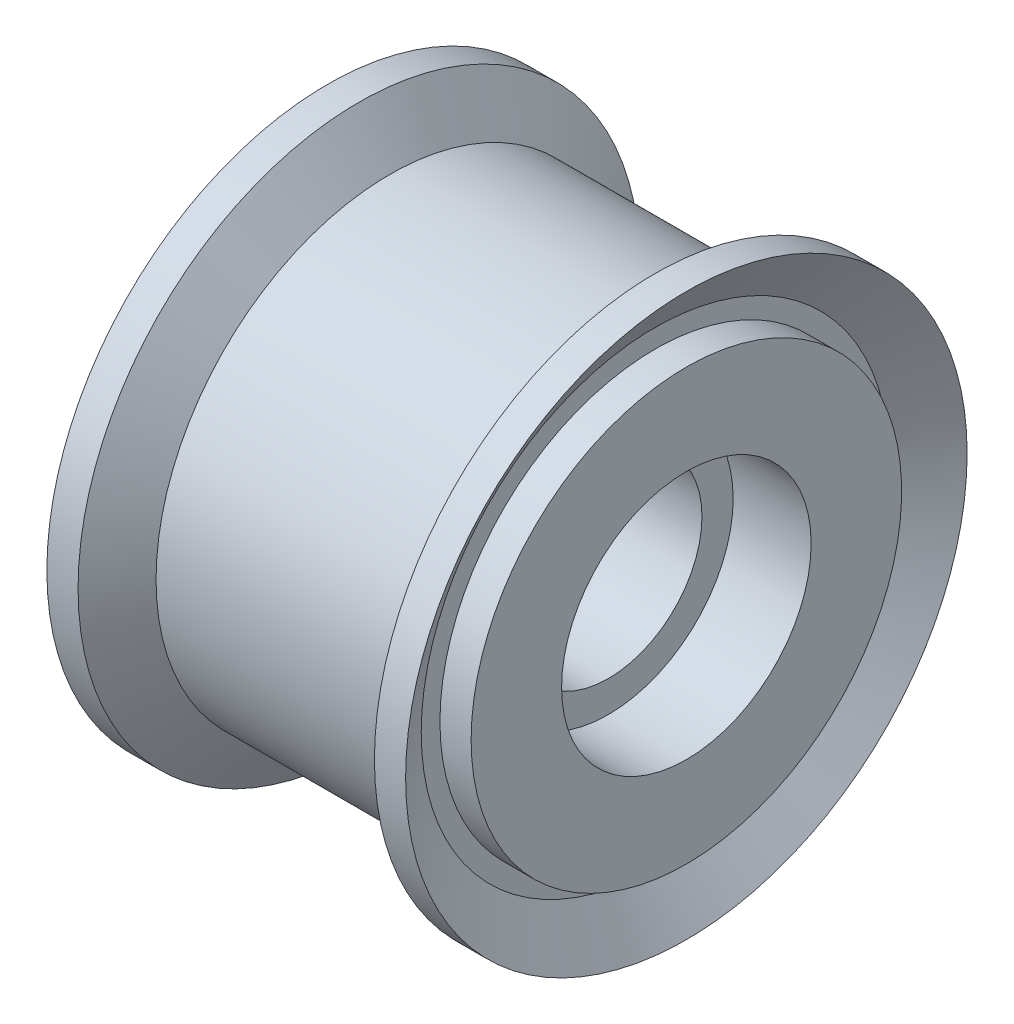
from build123d import *


with BuildPart() as part:
    # Sketch1 → Revolve1 (revolve)
    with BuildSketch(Plane.XY):
        Polygon((-5.75, 9), (-4.75, 7.5), (-4.75, 6.9), (-5.75, 6.9), (-5.75, 4), (-3.25, 4), (-3.25, 3), (3.25, 3), (3.25, 4), (5.75, 4), (5.75, 6.9), (4.75, 6.9), (4.75, 7.5), (5.75, 9), (4.75, 9), (3.75, 7.5), (-3.75, 7.5), (-4.75, 9), align=None)
    revolve(axis=Axis((5.75, 0, 0), (-1, 0, 0)))


solid = part.part
